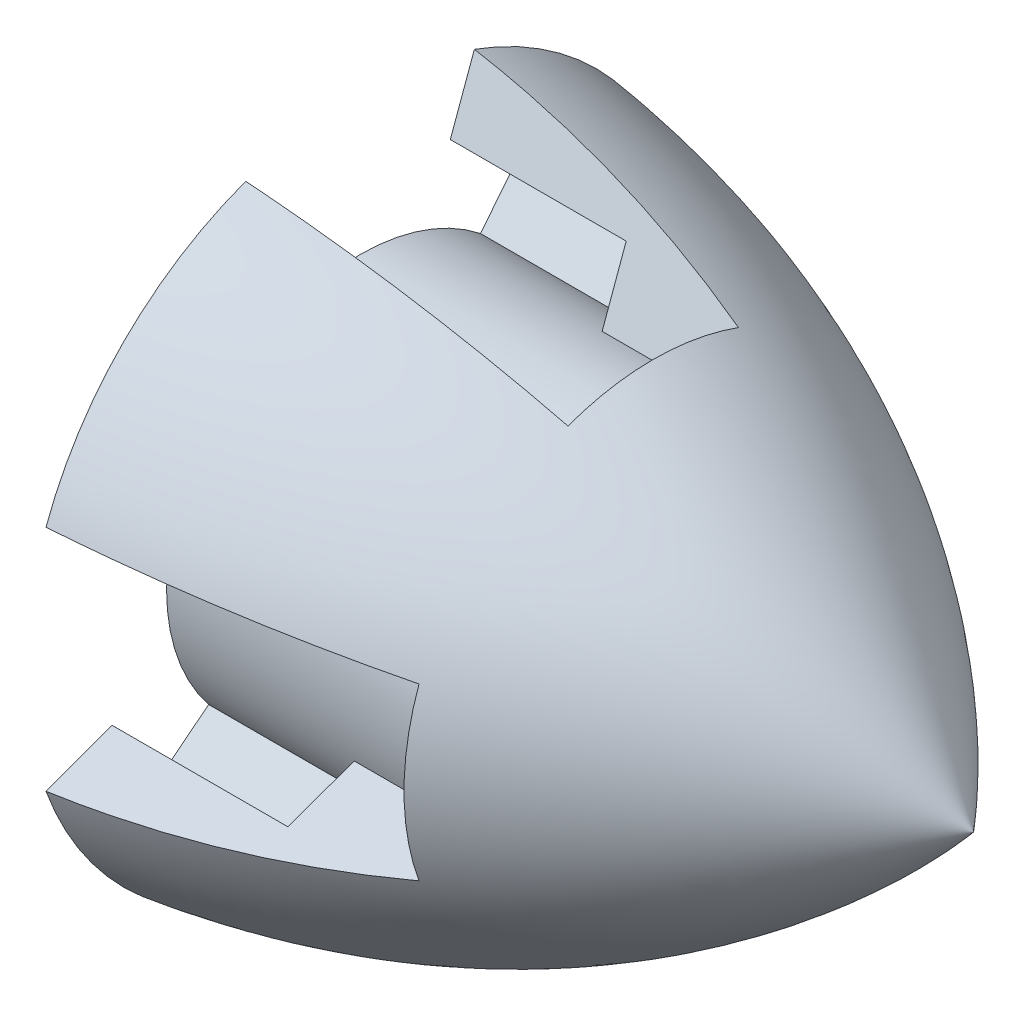
from build123d import *
from build123d.topology import SkipClean

# Parameters (mm, degrees)
SKETCH_7_R               = 12.6
CUT_EXTRUDE_1_DEPTH      = 15
SKETCH_8_R               = 16.5
CUT_EXTRUDE_2_DEPTH      = 1
CUT_EXTRUDE_3_DEPTH      = 25
PATTERN_CIRCULAR_1_COUNT = 4
SKETCH_12_R              = 16.5
SKETCH_12_R_2            = 12.6
EXTRUDE_1_DEPTH          = 1
CUT_EXTRUDE_4_DEPTH      = 15
PATTERN_CIRCULAR_2_COUNT = 4


with BuildPart() as part:
    # Эскиз2 → Повернуть1 (revolve)
    with BuildSketch(Plane.XY):
        with BuildLine():
            Line((0, 0), (0, 28.5))
            add(Edge.make_bspline(
                [(0, 28.5), (31.309007967, 24.448027272), (52.310724818, 0)],
                knots=[0, 0, 0, 1, 1, 1], degree=2))
            Line((52.310724818, 0), (28.5, 0))
            Line((28.5, 0), (0, 0))
        make_face()
    revolve(axis=Axis((-1000, 0, 0), (1, 0, 0)))

    # Эскиз7 → Вырез-Вытянуть1 (cut)
    with BuildSketch(Plane.ZY):
        Circle(SKETCH_7_R)
    extrude(amount=-CUT_EXTRUDE_1_DEPTH, mode=Mode.SUBTRACT)

    # Эскиз8 → Вырез-Вытянуть2 (cut)
    with BuildSketch(Plane.ZY):
        Circle(SKETCH_8_R)
    extrude(amount=-CUT_EXTRUDE_2_DEPTH, mode=Mode.SUBTRACT)

    # Эскиз11 → Вырез-Вытянуть3 (cut)
    with BuildSketch(Plane.ZY):
        with BuildLine():
            Line((-9.747574085, 26.781239692), (-7.695453225, 21.143083968))
            Line((-7.695453225, 21.143083968), (-5.643332365, 15.504928243))
            ThreePointArc((-5.643332365, 15.504928243), (0, 16.5), (5.643332365, 15.504928243))
            Line((5.643332365, 15.504928243), (7.695453225, 21.143083968))
            Line((7.695453225, 21.143083968), (9.747574085, 26.781239692))
            ThreePointArc((9.747574085, 26.781239692), (0, 28.5), (-9.747574085, 26.781239692))
        make_face()
    cut_extrude_3 = extrude(amount=-CUT_EXTRUDE_3_DEPTH, mode=Mode.SUBTRACT)

    # Круговой массив1: Вырез-Вытянуть3 ×4 about axis
    pattern_circular_1_axis = Axis((1, 0, 0), (-1, 0, 0))
    for i in range(1, PATTERN_CIRCULAR_1_COUNT):
        add(cut_extrude_3.rotate(pattern_circular_1_axis, i * 360 / PATTERN_CIRCULAR_1_COUNT), mode=Mode.SUBTRACT)

    # Эскиз12 → Бобышка-Вытянуть1 (add)
    with SkipClean():  # the faces are left unmerged after this step: merging them gives an invalid solid
        with BuildSketch(Plane.ZY.offset(-1)):
            Circle(SKETCH_12_R)
            Circle(SKETCH_12_R_2, mode=Mode.SUBTRACT)
        extrude(amount=EXTRUDE_1_DEPTH)

    # Эскиз13 → Вырез-Вытянуть4 (cut)
    with SkipClean():  # the faces are left unmerged after this step: merging them gives an invalid solid
        with BuildSketch(Plane.ZY):
            with BuildLine():
                Line((-14.006579324, 17.608683529), (-10.271491505, 12.913034588))
                ThreePointArc((-10.271491505, 12.913034588), (0, 16.5), (10.271491505, 12.913034588))
                Line((10.271491505, 12.913034588), (14.006579324, 17.608683529))
                ThreePointArc((14.006579324, 17.608683529), (0, 22.5), (-14.006579324, 17.608683529))
            make_face()
        cut_extrude_4 = extrude(amount=-CUT_EXTRUDE_4_DEPTH, mode=Mode.SUBTRACT)

    # Круговой массив2: Вырез-Вытянуть4 ×4 about axis
    with SkipClean():  # the faces are left unmerged after this step: merging them gives an invalid solid
        pattern_circular_2_axis = Axis((0, 0, 0), (-1, 0, 0))
        for i in range(1, PATTERN_CIRCULAR_2_COUNT):
            add(cut_extrude_4.rotate(pattern_circular_2_axis, i * 360 / PATTERN_CIRCULAR_2_COUNT), mode=Mode.SUBTRACT)


solid = part.part
